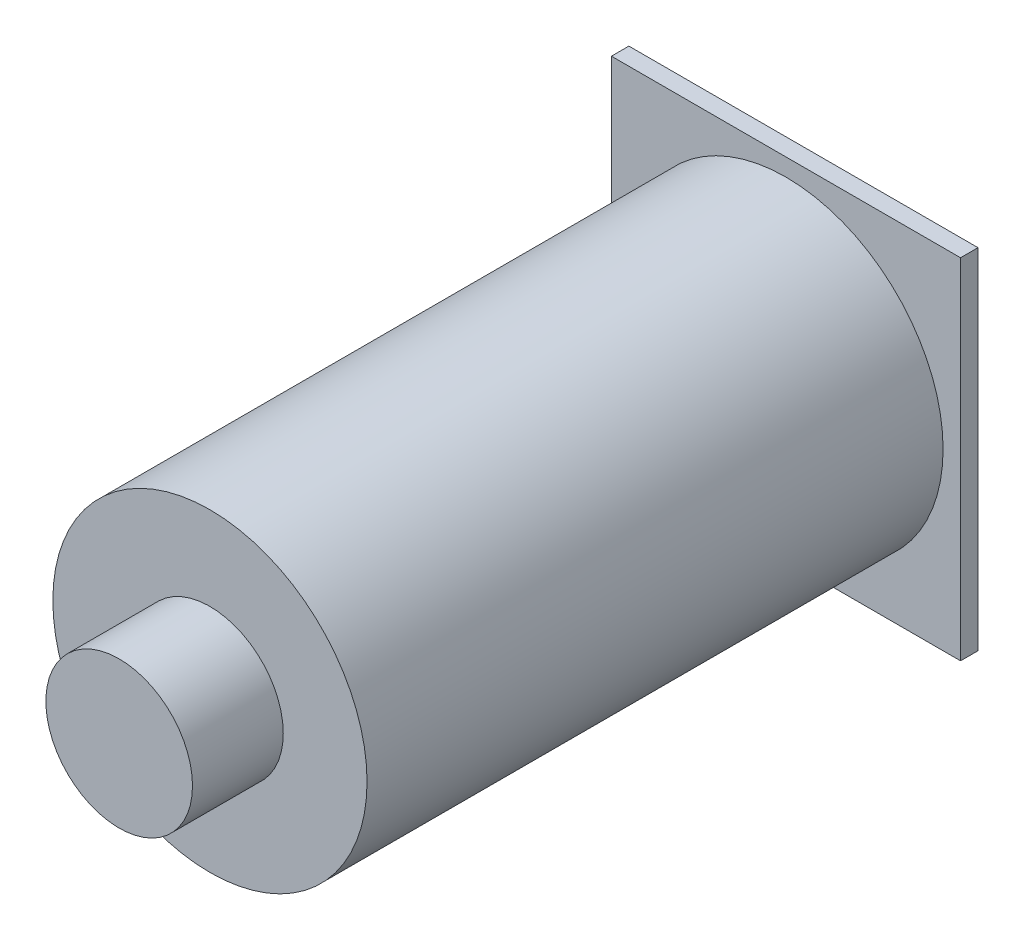
from build123d import *

# Parameters (mm, degrees)
SKETCH1_W           = 127
SKETCH1_H           = 127
BOSS_EXTRUDE1_DEPTH = 6.35
SKETCH2_R           = 57.15
BOSS_EXTRUDE2_DEPTH = 209.55
SKETCH3_R           = 26.67
BOSS_EXTRUDE3_DEPTH = 33.02


with BuildPart() as part:
    # Sketch1 → Boss-Extrude1 (new body)
    with BuildSketch(Plane.XY):
        Rectangle(SKETCH1_W, SKETCH1_H)
    extrude(amount=BOSS_EXTRUDE1_DEPTH)

    # Sketch2 → Boss-Extrude2 (add)
    with BuildSketch(Plane.XY.offset(6.35)):
        Circle(SKETCH2_R)
    extrude(amount=BOSS_EXTRUDE2_DEPTH)

    # Sketch3 → Boss-Extrude3 (add)
    with BuildSketch(Plane.XY.offset(215.9)):
        Circle(SKETCH3_R)
    extrude(amount=BOSS_EXTRUDE3_DEPTH)


solid = part.part
